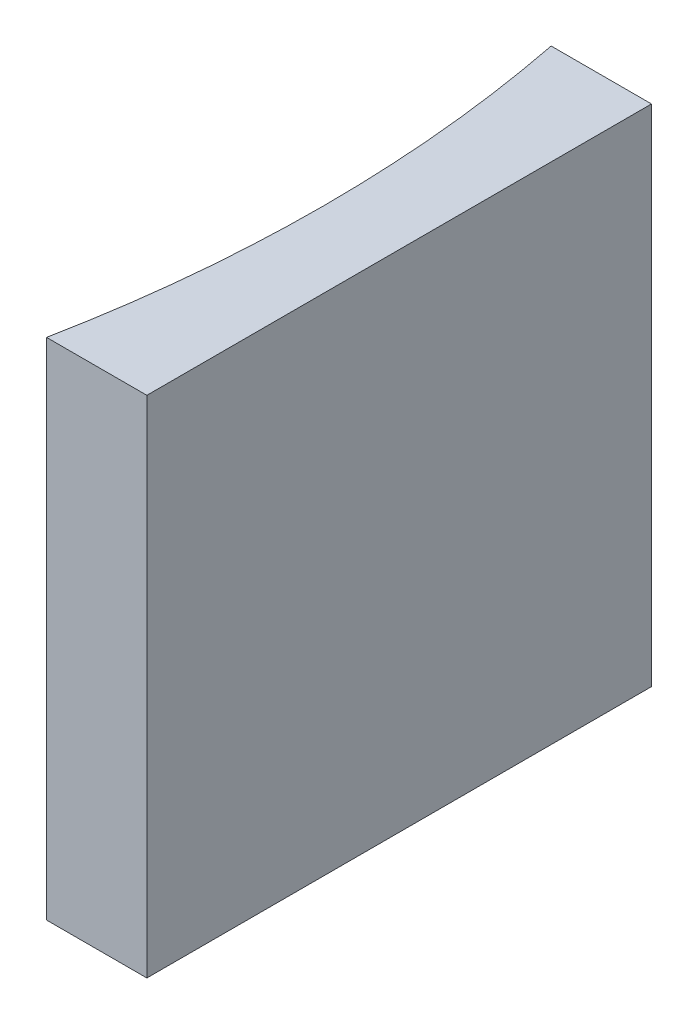
from build123d import *

# Parameters (mm, degrees)
EXTRUDE_1_DEPTH = 20


with BuildPart() as part:
    # 草图1 → 凸台-拉伸1 (new body)
    with BuildSketch(Plane(origin=(0, 0, 0), x_dir=(1, 0, 0), z_dir=(0, 1, 0))):
        with BuildLine():
            Line((0, 0), (0, -20))
            Line((0, -20), (-3.977493153, -20))
            ThreePointArc((-3.977493153, -20), (-3, -10), (-3.977493153, 0))
            Line((-3.977493153, 0), (0, 0))
        make_face()
    extrude(amount=EXTRUDE_1_DEPTH)


solid = part.part
